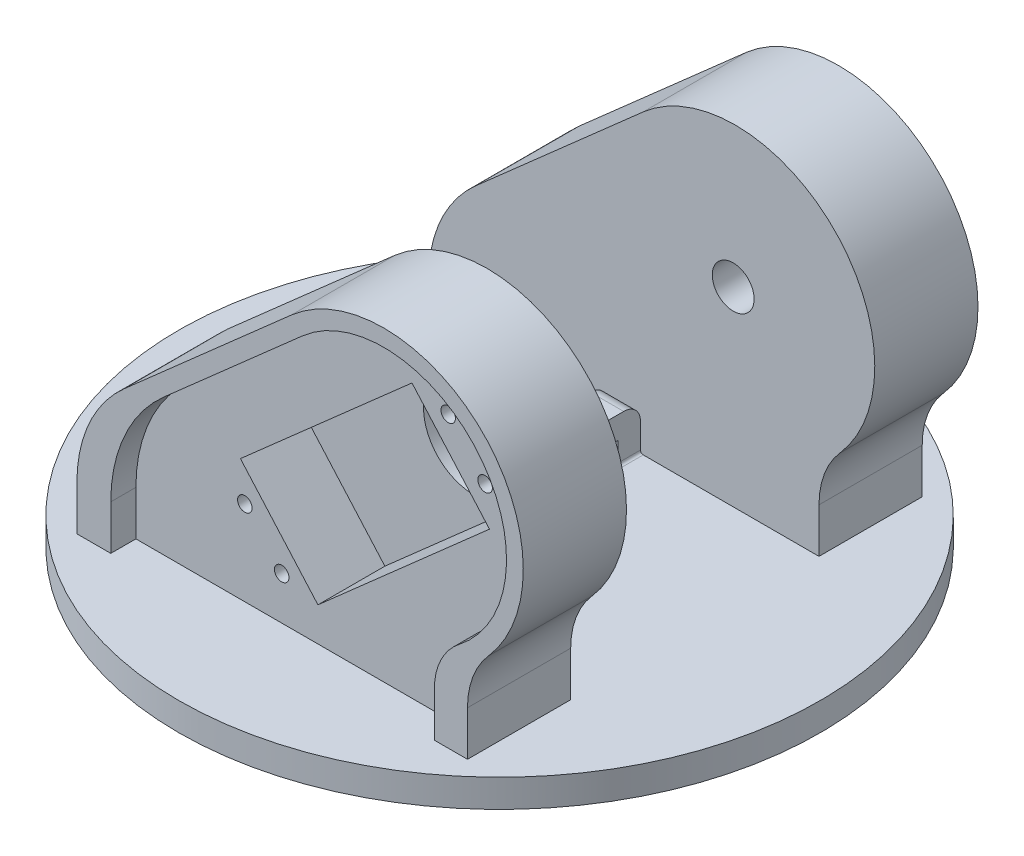
from build123d import *

# Parameters (mm, degrees)
SKETCH1_R           = 57.5
BOSS_EXTRUDE1_DEPTH = 5
BOSS_EXTRUDE2_DEPTH = 40.75
CUT_EXTRUDE1_DEPTH  = 22.25
CUT_EXTRUDE2_DEPTH  = 4.5
CUT_EXTRUDE3_DEPTH  = 12
SKETCH7_R           = 9
CUT_EXTRUDE5_DEPTH  = 2
SKETCH8_R           = 1.3
CUT_EXTRUDE6_DEPTH  = 7.5
SKETCH10_R          = 3.75
CUT_EXTRUDE7_DEPTH  = 14
SKETCH11_R          = 3.75
CUT_EXTRUDE8_DEPTH  = 2
CUT_EXTRUDE9_REACH  = 66.458
SKETCH12_R          = 0.85
BOSS_EXTRUDE3_DEPTH = 3
FILLET1_R           = 0.5


with BuildPart() as part:
    # Sketch1 → Boss-Extrude1 (new body)
    with BuildSketch(Plane(origin=(0, 0, 0), x_dir=(1, 0, 0), z_dir=(0, 1, 0))):
        Circle(SKETCH1_R)
    extrude(amount=BOSS_EXTRUDE1_DEPTH)

    # Sketch2 → Boss-Extrude2 (add, symmetric)
    with BuildSketch(Plane.XY):
        with BuildLine():
            Line((-35, 5), (-35, 13))
            ThreePointArc((-35, 13), (-32.785945694, 23.285945694), (-26.535945694, 31.75))
            Line((-26.535945694, 31.75), (3.464054306, 58.207513111))
            ThreePointArc((3.464054306, 58.207513111), (37.67766953, 57.13518264), (38.75, 22.921567416))
            ThreePointArc((38.75, 22.921567416), (35.9687848, 18.303300859), (35, 13))
            Line((35, 13), (35, 5))
            Line((35, 5), (-35, 5))
        make_face()
    extrude(amount=BOSS_EXTRUDE2_DEPTH, both=True)

    # Sketch4 → Cut-Extrude1 (cut, symmetric)
    with BuildSketch(Plane.XY):
        with BuildLine():
            Line((3.464054306, 58.207513111), (-26.535945694, 31.75))
            ThreePointArc((-26.535945694, 31.75), (-32.785945694, 23.285945694), (-35, 13))
            Line((-35, 13), (-35, 5))
            Line((-35, 5), (35, 5))
            Line((35, 5), (35, 13))
            ThreePointArc((35, 13), (35.9687848, 18.303300859), (38.75, 22.921567416))
            ThreePointArc((38.75, 22.921567416), (37.67766953, 57.13518264), (3.464054306, 58.207513111))
        make_face()
    extrude(amount=CUT_EXTRUDE1_DEPTH, both=True, mode=Mode.SUBTRACT)

    # Sketch5 → Cut-Extrude2 (cut)
    with BuildSketch(Plane.XY.offset(40.75)):
        with BuildLine():
            Line((5.448367789, 55.957513111), (-19.449111825, 34))
            ThreePointArc((-19.449111825, 34), (-26.449111825, 24.520259177), (-28.928852648, 13))
            Line((-28.928852648, 13), (-28.928852648, 5))
            Line((-28.928852648, 5), (29.071147352, 5))
            Line((29.071147352, 5), (29.071147352, 13))
            ThreePointArc((29.071147352, 13), (30.242434209, 18.064703602), (33.518438806, 22.100905947))
            ThreePointArc((33.518438806, 22.100905947), (36.936184172, 53.499082314), (5.448367789, 55.957513111))
        make_face()
    cut_extrude2 = extrude(amount=-CUT_EXTRUDE2_DEPTH, mode=Mode.SUBTRACT)

    # Mirror1: Cut-Extrude2 across plane
    add(cut_extrude2.mirror(Plane.XY), mode=Mode.SUBTRACT)

    # Sketch6 → Cut-Extrude3 (cut)
    with BuildSketch(Plane.XY.offset(36.25)):
        Polygon((20.554902808, 53.946891388), (-10.195097192, 26.82794045), (3.695097192, 11.07794045), (34.445097192, 38.196891388), align=None)
    extrude(amount=-CUT_EXTRUDE3_DEPTH, mode=Mode.SUBTRACT)

    # Sketch7 → Cut-Extrude5 (cut)
    with BuildSketch(Plane.XY.offset(24.25)):
        with Locations((19.625, 39.126794197)):
            Circle(SKETCH7_R)
    extrude(amount=-CUT_EXTRUDE5_DEPTH, mode=Mode.SUBTRACT)

    # Sketch8 → Cut-Extrude6 (cut)
    with BuildSketch(Plane.XY.offset(36.25)):
        with Locations((27.042810861, 52.335355134)):
            Circle(SKETCH8_R)
        with Locations((33.657189139, 44.835355134)):
            Circle(SKETCH8_R)
        with Locations((-9.407189139, 20.189476704)):
            Circle(SKETCH8_R)
        with Locations((-2.792810861, 12.689476704)):
            Circle(SKETCH8_R)
    extrude(amount=-CUT_EXTRUDE6_DEPTH, mode=Mode.SUBTRACT)

    # Sketch10 → Cut-Extrude7 (cut)
    with BuildSketch(Plane.XY.offset(-22.25)):
        with Locations((19.625, 39.126794197)):
            Circle(SKETCH10_R)
    extrude(amount=-CUT_EXTRUDE7_DEPTH, mode=Mode.SUBTRACT)

    # Sketch11 → Cut-Extrude8 (cut)
    with BuildSketch(Plane.XZ):
        Circle(SKETCH11_R)
    extrude(amount=-CUT_EXTRUDE8_DEPTH, mode=Mode.SUBTRACT)

    # Sketch12 → Cut-Extrude9 (cut, up to next)
    with BuildSketch(Plane.XZ, mode=Mode.PRIVATE) as cut_extrude9_sk1:
        with Locations((7, 0)):
            Circle(SKETCH12_R)
    cut_extrude9_tool1 = extrude(cut_extrude9_sk1.sketch, amount=-CUT_EXTRUDE9_REACH, mode=Mode.PRIVATE) & part.part
    add(cut_extrude9_tool1.solids().sort_by_distance((7, 0, 0))[0], mode=Mode.SUBTRACT)
    # Sketch12 → Cut-Extrude9 (cut, up to next)
    with BuildSketch(Plane.XZ, mode=Mode.PRIVATE) as cut_extrude9_sk2:
        with Locations((-7, 0)):
            Circle(SKETCH12_R)
    cut_extrude9_tool2 = extrude(cut_extrude9_sk2.sketch, amount=-CUT_EXTRUDE9_REACH, mode=Mode.PRIVATE) & part.part
    add(cut_extrude9_tool2.solids().sort_by_distance((-7, 0, 0))[0], mode=Mode.SUBTRACT)

    # Sketch13 → Boss-Extrude3 (add, symmetric)
    with BuildSketch(Plane(origin=(0, 0, 0), x_dir=(0, 0, -1), z_dir=(1, 0, 0))):
        with BuildLine():
            Line((22.25, 5), (22.25, 10))
            ThreePointArc((22.25, 10), (21.371320344, 12.121320344), (19.25, 13))
            Line((19.25, 13), (9.25, 13))
            ThreePointArc((9.25, 13), (7.128679656, 12.121320344), (6.25, 10))
            Line((6.25, 10), (6.25, 5))
            Line((6.25, 5), (10.25, 5))
            Line((10.25, 5), (10.25, 9))
            Line((10.25, 9), (18.25, 9))
            Line((18.25, 9), (18.25, 5))
            Line((18.25, 5), (22.25, 5))
        make_face()
    extrude(amount=BOSS_EXTRUDE3_DEPTH, both=True)

    # Fillet1
    fillet1_edges = [part.edges().sort_by_distance(p)[0] for p in [
        (-3, 5, -20.25),
        (0, 5, -18.25),
        (-3, 5, -8.25),
        (0, 5, -6.25),
        (0, 5, -10.25),
        (3, 5, -20.25),
        (3, 5, -8.25),
    ]]
    fillet(fillet1_edges, radius=FILLET1_R)


solid = part.part
